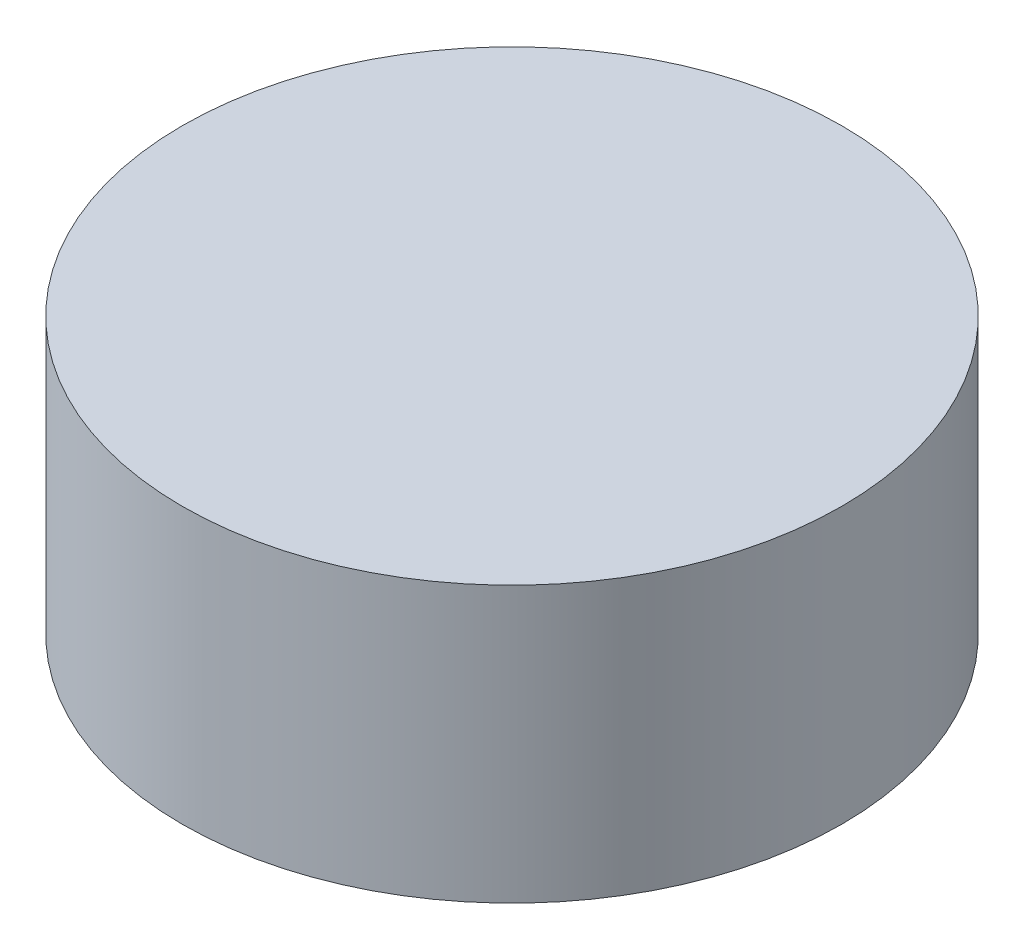
from build123d import *

# Parameters (mm, degrees)
SKIZZE2_R                       = 23.946630382
AUFSATZ_LINEAR_AUSTRAGEN1_DEPTH = 10


with BuildPart() as part:
    # Skizze2 → Aufsatz-Linear austragen1 (new body, symmetric)
    with BuildSketch(Plane(origin=(0, 0, 0), x_dir=(1, 0, 0), z_dir=(0, 1, 0))):
        Circle(SKIZZE2_R)
    extrude(amount=AUFSATZ_LINEAR_AUSTRAGEN1_DEPTH, both=True)


solid = part.part
